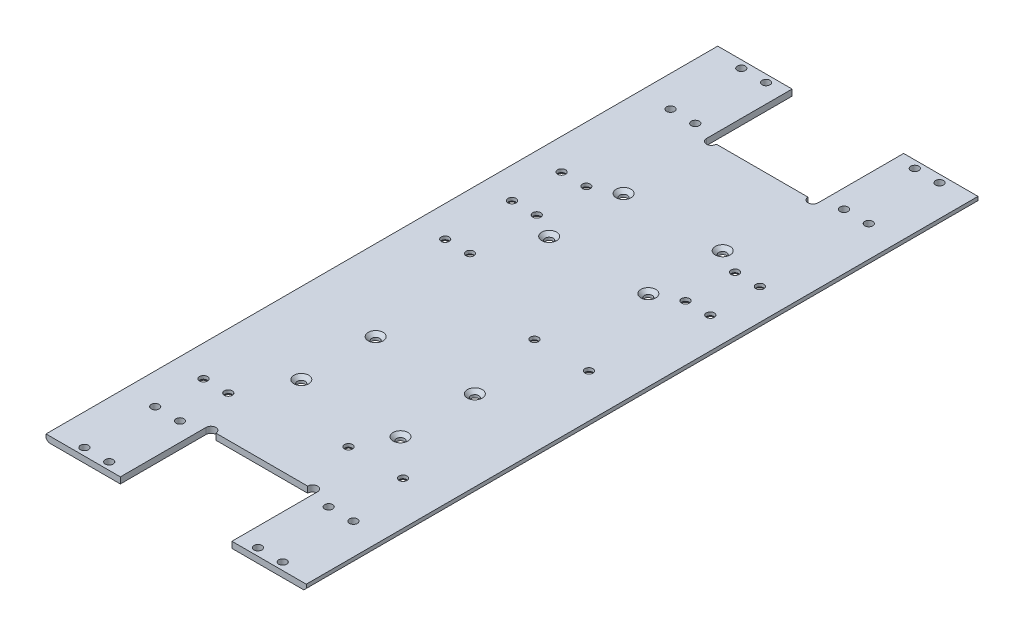
from build123d import *

# Parameters (mm, degrees)
SKETCH_1_W          = 105
SKETCH_1_H          = 271
EXTRUDE_1_DEPTH     = 2.5
SKETCH_2_R          = 1.6
CUT_EXTRUDE_1_DEPTH = 10
CHAMFER_4_SIZE      = 1.4
CHAMFER_5_SIZE      = 1
CUT_EXTRUDE_2_DEPTH = 10
SKETCH_6_R          = 1.6
CUT_EXTRUDE_3_DEPTH = 10
SKETCH_7_R          = 1.6
CUT_EXTRUDE_4_DEPTH = 10
SKETCH_8_R          = 1.6
CUT_EXTRUDE_5_DEPTH = 10
SKETCH_9_R          = 2
CUT_EXTRUDE_6_DEPTH = 10
CHAMFER_3_SIZE      = 1.2


with BuildPart() as part:
    # 草图1 → 凸台-拉伸1 (new body)
    with BuildSketch(Plane(origin=(0, 0, 0), x_dir=(1, 0, 0), z_dir=(0, 1, 0))):
        Rectangle(SKETCH_1_W, SKETCH_1_H)
    extrude(amount=EXTRUDE_1_DEPTH)

    # 草图2 → 切除-拉伸1 (cut)
    with BuildSketch(Plane(origin=(0, 2.5, 0), x_dir=(1, 0, 0), z_dir=(0, 1, 0))):
        with Locations((35, -3.95)):
            Circle(SKETCH_2_R)
        with Locations((13.000000181, -3.95)):
            Circle(SKETCH_2_R)
        with Locations((35, -78.95)):
            Circle(SKETCH_2_R)
        with Locations((13.000000181, -78.95)):
            Circle(SKETCH_2_R)
        with Locations((20, -35)):
            Circle(SKETCH_2_R)
        with Locations((-20, -35)):
            Circle(SKETCH_2_R)
        with Locations((20, -65)):
            Circle(SKETCH_2_R)
        with Locations((-20, -65)):
            Circle(SKETCH_2_R)
        with Locations((-20, 35)):
            Circle(SKETCH_2_R)
        with Locations((20, 35)):
            Circle(SKETCH_2_R)
        with Locations((-20, 65)):
            Circle(SKETCH_2_R)
        with Locations((20, 65)):
            Circle(SKETCH_2_R)
    extrude(amount=-CUT_EXTRUDE_1_DEPTH, mode=Mode.SUBTRACT)

    # 倒角4
    chamfer_4_edges = [part.edges().sort_by_distance(p)[0] for p in [
        (-21.6, 2.5, 35),
        (18.4, 2.5, 65),
        (-21.6, 2.5, 65),
        (-21.6, 2.5, -35),
        (18.4, 2.5, 35),
        (18.4, 2.5, -65),
        (-21.6, 2.5, -65),
        (18.4, 2.5, -35),
    ]]
    chamfer(chamfer_4_edges, length=CHAMFER_4_SIZE)

    # 倒角5
    chamfer_5_edges = [part.edges().sort_by_distance(p)[0] for p in [
        (-52.5, 0, 0),
        (52.5, 0, 0),
    ]]
    chamfer(chamfer_5_edges, length=CHAMFER_5_SIZE)

    # 草图4 → 切除-拉伸2 (cut)
    with BuildSketch(Plane.XZ):
        Polygon((0, 100.95), (22.5, 100.95), (22.5, 135.5), (-22.5, 135.5), (-22.5, 100.95), align=None)
        Polygon((-22.5, -100.95), (0, -100.95), (22.5, -100.95), (22.5, -135.5), (-22.5, -135.5), align=None)
    extrude(amount=-CUT_EXTRUDE_2_DEPTH, mode=Mode.SUBTRACT)

    # 草图6 → 切除-拉伸3 (cut)
    with BuildSketch(Plane.XZ):
        with Locations((-40, 132.5)):
            Circle(SKETCH_6_R)
        with Locations((-30, 132.5)):
            Circle(SKETCH_6_R)
        with Locations((-30, 103.95)):
            Circle(SKETCH_6_R)
        with Locations((-40, 103.95)):
            Circle(SKETCH_6_R)
        with Locations((40, 103.95)):
            Circle(SKETCH_6_R)
        with Locations((30, 103.95)):
            Circle(SKETCH_6_R)
        with Locations((30, 132.5)):
            Circle(SKETCH_6_R)
        with Locations((40, 132.5)):
            Circle(SKETCH_6_R)
        with Locations((40, -132.5)):
            Circle(SKETCH_6_R)
        with Locations((30, -132.5)):
            Circle(SKETCH_6_R)
        with Locations((30, -103.95)):
            Circle(SKETCH_6_R)
        with Locations((40, -103.95)):
            Circle(SKETCH_6_R)
        with Locations((-40, -103.95)):
            Circle(SKETCH_6_R)
        with Locations((-30, -103.95)):
            Circle(SKETCH_6_R)
        with Locations((-30, -132.5)):
            Circle(SKETCH_6_R)
        with Locations((-40, -132.5)):
            Circle(SKETCH_6_R)
    extrude(amount=-CUT_EXTRUDE_3_DEPTH, mode=Mode.SUBTRACT)

    # 草图7 → 切除-拉伸4 (cut)
    with BuildSketch(Plane(origin=(0, 2.5, 0), x_dir=(1, 0, 0), z_dir=(0, 1, 0))):
        with Locations((-40, 60)):
            Circle(SKETCH_7_R)
        with Locations((-30, 60)):
            Circle(SKETCH_7_R)
        with Locations((30, 60)):
            Circle(SKETCH_7_R)
        with Locations((40, 60)):
            Circle(SKETCH_7_R)
        with Locations((-40, 40)):
            Circle(SKETCH_7_R)
        with Locations((-30, 40)):
            Circle(SKETCH_7_R)
        with Locations((30, 40)):
            Circle(SKETCH_7_R)
        with Locations((40, 40)):
            Circle(SKETCH_7_R)
    extrude(amount=-CUT_EXTRUDE_4_DEPTH, mode=Mode.SUBTRACT)

    # 草图8 → 切除-拉伸5 (cut)
    with BuildSketch(Plane.XZ):
        with Locations((-40, 84.45)):
            Circle(SKETCH_8_R)
        with Locations((-30, 84.45)):
            Circle(SKETCH_8_R)
        with Locations((-30, -13.05)):
            Circle(SKETCH_8_R)
        with Locations((-40, -13.05)):
            Circle(SKETCH_8_R)
    extrude(amount=-CUT_EXTRUDE_5_DEPTH, mode=Mode.SUBTRACT)

    # 草图9 → 切除-拉伸6 (cut)
    with BuildSketch(Plane.XZ):
        with Locations((20.5, 100.95)):
            Circle(SKETCH_9_R)
        with Locations((-20.5, 100.95)):
            Circle(SKETCH_9_R)
        with Locations((-20.5, -100.95)):
            Circle(SKETCH_9_R)
        with Locations((20.5, -100.95)):
            Circle(SKETCH_9_R)
    extrude(amount=-CUT_EXTRUDE_6_DEPTH, mode=Mode.SUBTRACT)

    # 倒角3
    chamfer_3_edges = [part.edges().sort_by_distance(p)[0] for p in [
        (28.4, 0, -40),
        (-31.6, 0, -60),
        (38.4, 0, -60),
        (-41.6, 0, -60),
        (-31.6, 0, -40),
        (38.4, 0, -40),
        (-41.6, 0, -40),
        (28.4, 0, -60),
        (-41.6, 0, -13.05),
        (-31.6, 0, -13.05),
        (-31.6, 0, 84.45),
        (-41.6, 0, 84.45),
        (11.400000181, 0, 3.95),
        (33.4, 0, 78.95),
        (11.400000181, 0, 78.95),
        (33.4, 0, 3.95),
    ]]
    chamfer(chamfer_3_edges, length=CHAMFER_3_SIZE)


solid = part.part
